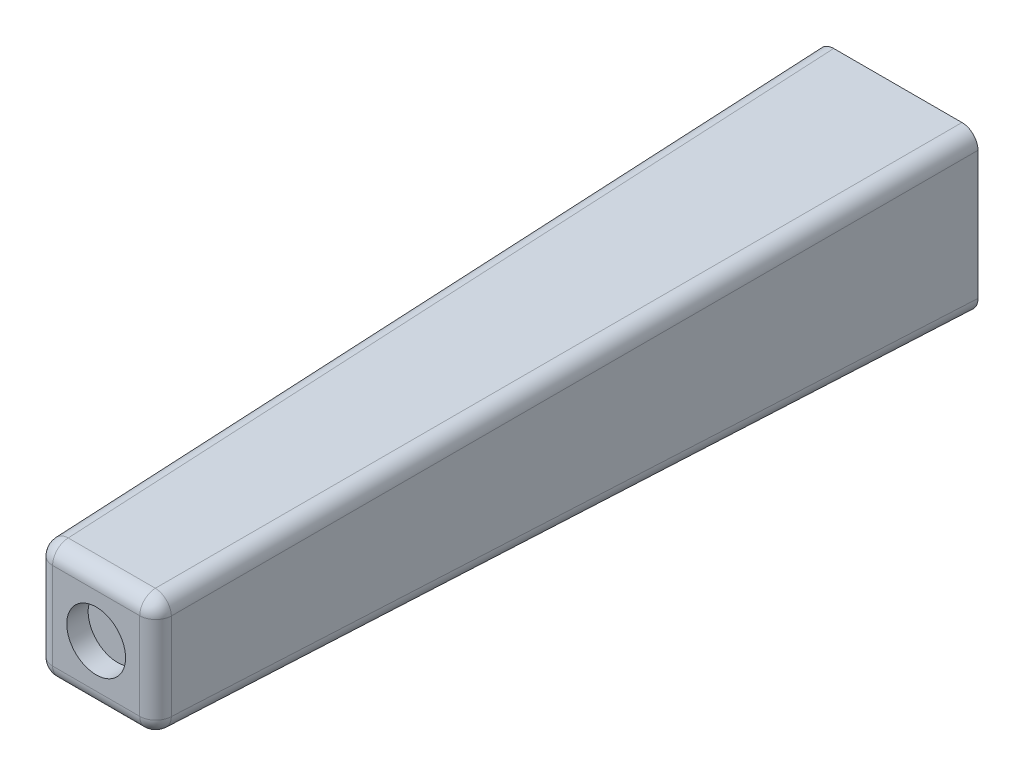
from build123d import *

# Parameters (mm, degrees)
SKETCH1_W           = 15
SKETCH1_H           = 15
BOSS_EXTRUDE1_DEPTH = 75
BOSS_EXTRUDE1_TAPER = 1.5
SKETCH2_R           = 1.5
CUT_EXTRUDE1_DEPTH  = 10
SKETCH3_R           = 2.75
CUT_EXTRUDE2_DEPTH  = 2
FILLET1_R           = 1.5
FILLET2_R           = 0.5


with BuildPart() as part:
    # Sketch1 → Boss-Extrude1 (new body)
    with BuildSketch(Plane.XY):
        Rectangle(SKETCH1_W, SKETCH1_H)
    extrude(amount=BOSS_EXTRUDE1_DEPTH, taper=BOSS_EXTRUDE1_TAPER)

    # Sketch2 → Cut-Extrude1 (cut)
    with BuildSketch(Plane(origin=(0, 0, 0), x_dir=(-1, 0, 0), z_dir=(0, 0, -1))):
        Circle(SKETCH2_R)
    extrude(amount=-CUT_EXTRUDE1_DEPTH, mode=Mode.SUBTRACT)

    # Sketch3 → Cut-Extrude2 (cut)
    with BuildSketch(Plane.XY.offset(75)):
        Circle(SKETCH3_R)
    extrude(amount=-CUT_EXTRUDE2_DEPTH, mode=Mode.SUBTRACT)

    # Fillet1
    fillet1_edges = [part.edges().sort_by_distance(p)[0] for p in [
        (-5.536055882, 0, 75),
        (0, -5.536055882, 75),
        (5.536055882, 0, 75),
        (6.518027941, -6.518027941, 37.5),
        (-6.518027941, -6.518027941, 37.5),
        (-6.518027479, 6.518027479, 37.500017641),
        (6.518027941, 6.518027941, 37.5),
        (0, 5.536055882, 75),
    ]]
    fillet(fillet1_edges, radius=FILLET1_R)

    # Fillet2
    fillet2_edges = [part.edges().sort_by_distance(p)[0] for p in [
        (1.5, 0, 0),
    ]]
    fillet(fillet2_edges, radius=FILLET2_R)


solid = part.part
